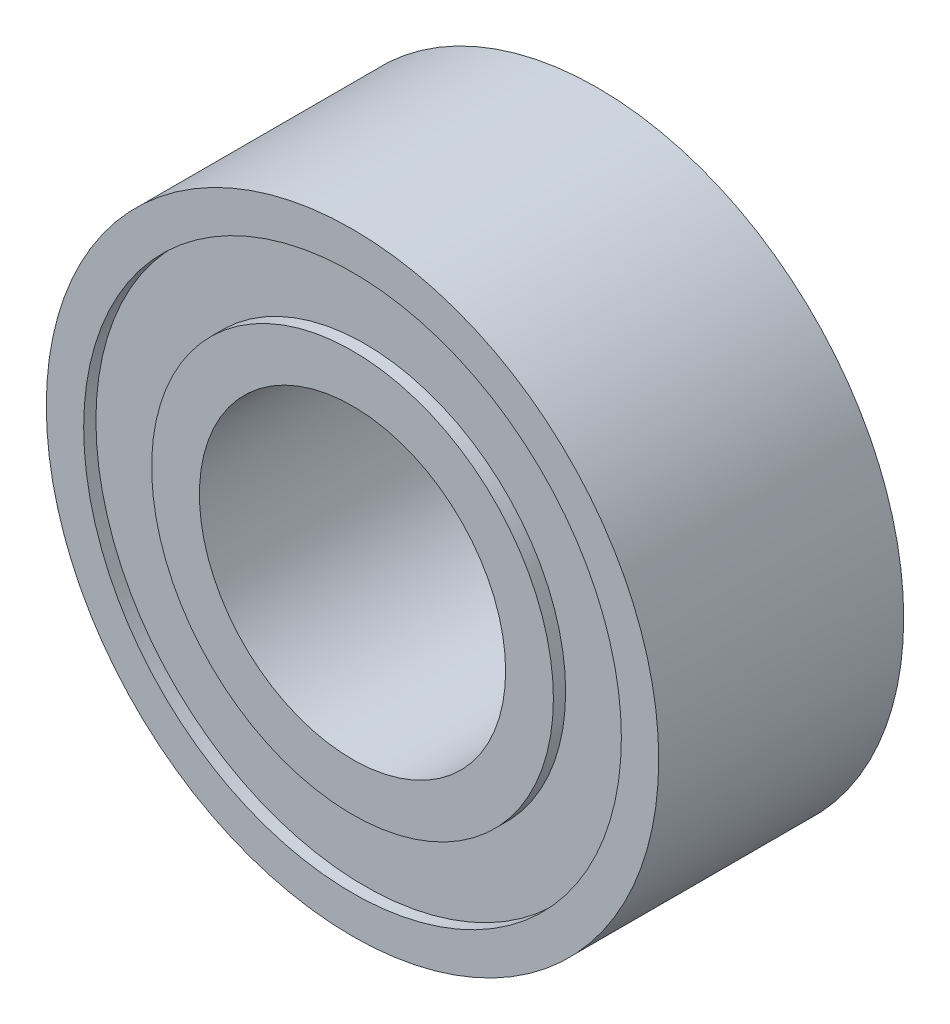
from build123d import *

# Parameters (mm, degrees)
SKETCH1_R           = 5
SKETCH1_R_2         = 2.5
BOSS_EXTRUDE1_DEPTH = 2
SKETCH2_R           = 4.39
SKETCH2_R_2         = 3.28
CUT_EXTRUDE1_DEPTH  = 0.2


with BuildPart() as part:
    # Sketch1 → Boss-Extrude1 (new body, symmetric)
    with BuildSketch(Plane.XY):
        Circle(SKETCH1_R)
        Circle(SKETCH1_R_2, mode=Mode.SUBTRACT)
    extrude(amount=BOSS_EXTRUDE1_DEPTH, both=True)

    # Sketch2 → Cut-Extrude1 (cut)
    with BuildSketch(Plane.XY.offset(2)):
        Circle(SKETCH2_R)
        Circle(SKETCH2_R_2, mode=Mode.SUBTRACT)
    cut_extrude1 = extrude(amount=-CUT_EXTRUDE1_DEPTH, mode=Mode.SUBTRACT)

    # Mirror1: Cut-Extrude1 across plane
    add(cut_extrude1.mirror(Plane.XY), mode=Mode.SUBTRACT)


solid = part.part
